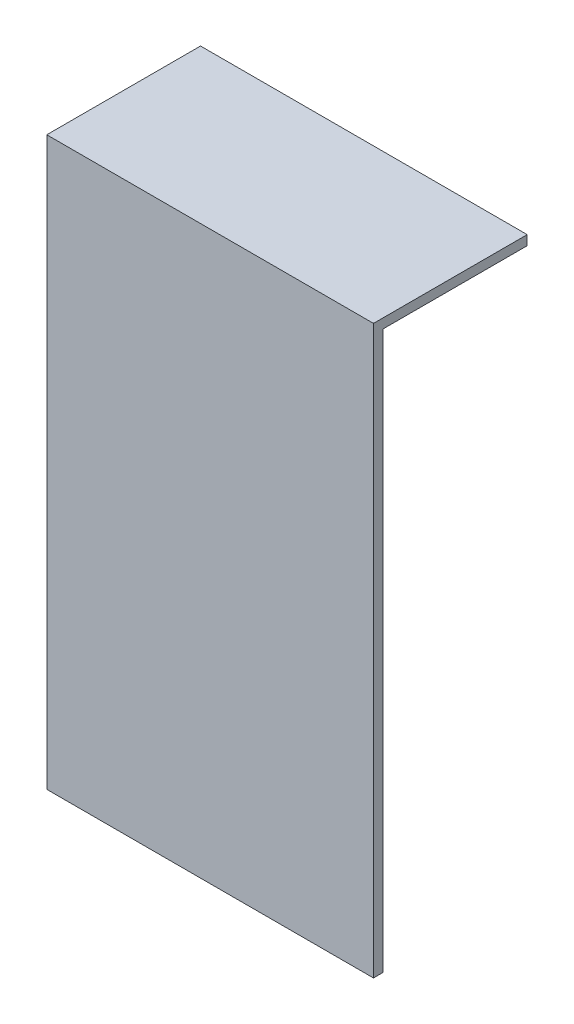
from build123d import *

# Parameters (mm, degrees)
SKETCH1_W           = 86.36
SKETCH1_H           = 2.54
BOSS_EXTRUDE1_DEPTH = 149.86
SKETCH2_W           = 86.36
SKETCH2_H           = 2.54
BOSS_EXTRUDE2_DEPTH = 38.1


with BuildPart() as part:
    # Sketch1 → Boss-Extrude1 (new body)
    with BuildSketch(Plane(origin=(0, 0, 0), x_dir=(1, 0, 0), z_dir=(0, 1, 0))):
        Rectangle(SKETCH1_W, SKETCH1_H)
    extrude(amount=BOSS_EXTRUDE1_DEPTH)

    # Sketch2 → Boss-Extrude2 (add)
    with BuildSketch(Plane(origin=(0, 0, -1.27), x_dir=(-1, 0, 0), z_dir=(0, 0, -1))):
        with Locations((0, 148.59)):
            Rectangle(SKETCH2_W, SKETCH2_H)
    extrude(amount=BOSS_EXTRUDE2_DEPTH)


solid = part.part
